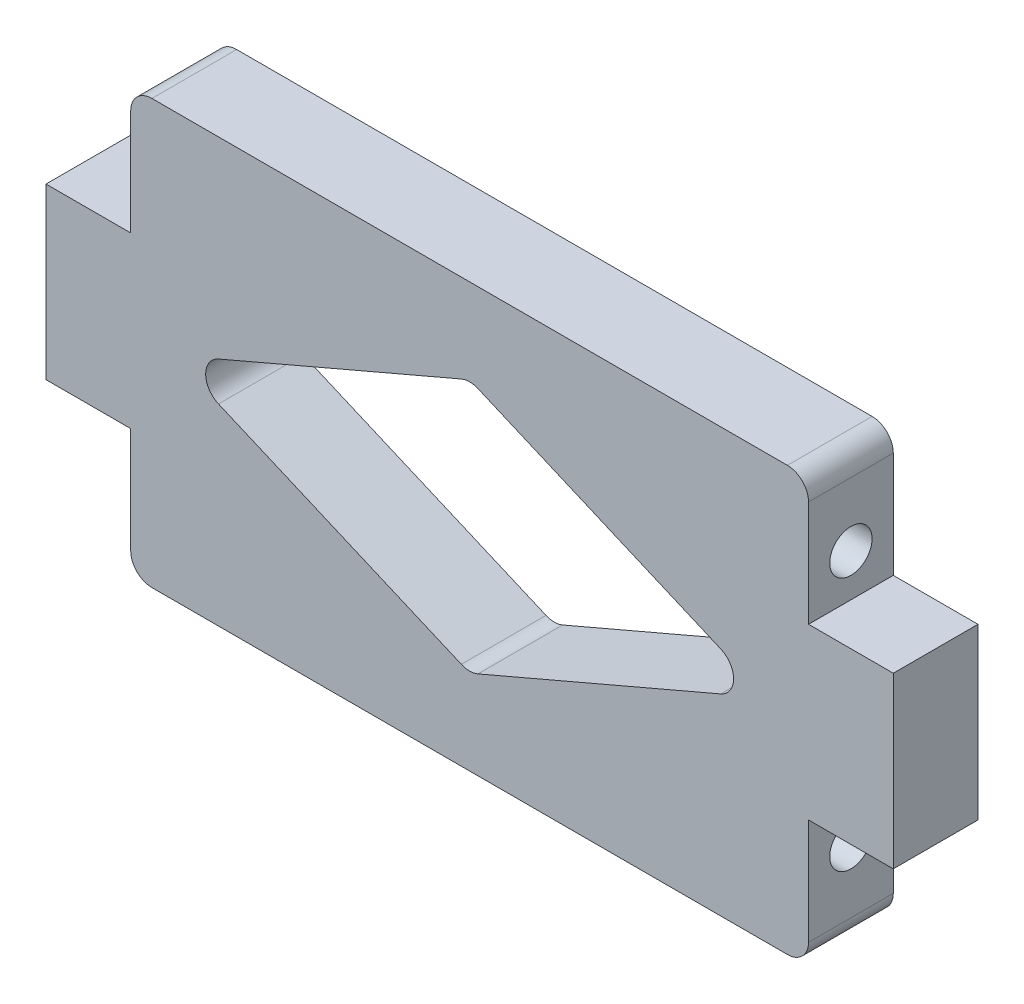
from build123d import *

# Parameters (mm, degrees)
SKETCH1_W                        = 12.7
SKETCH1_H                        = 25.4
SKETCH1_W_2                      = 101.6
SKETCH1_H_2                      = 63.5
BOSS_EXTRUDE1_DEPTH              = 12.7
F_1_4_20_TAPPED_HOLE1_AT_2_COUNT = 2
F_1_4_20_TAPPED_HOLE1_AT_2_PITCH = 38.1
CUT_EXTRUDE1_DEPTH               = 13.7
FILLET1_R                        = 3.175
FILLET2_R                        = 3.175


with BuildPart() as part:
    # Sketch1 → Boss-Extrude1 (new body)
    with BuildSketch(Plane.XY):
        with Locations((-57.15, 0)):
            Rectangle(SKETCH1_W, SKETCH1_H)
        Rectangle(SKETCH1_W_2, SKETCH1_H_2)
        with Locations((57.15, 0)):
            Rectangle(SKETCH1_W, SKETCH1_H)
    extrude(amount=BOSS_EXTRUDE1_DEPTH)

    # Sketch2 → 1/4-20 Tapped Hole1 (revolve, cut)
    with BuildSketch(Plane(origin=(50.8, 19.05, 6.35), x_dir=(0, 0, -1), z_dir=(0, 1, 0))):
        Polygon((0, 0), (0, 18.043816902), (2.5527, 16.51), (2.5527, 12.7), (3.175, 12.7), (3.175, 0), align=None)
    f_1_4_20_tapped_hole1 = revolve(axis=Axis((57.15, 19.05, 6.35), (-1, 0, 0)), mode=Mode.SUBTRACT)

    # 1/4-20 Tapped Hole1 at 2: 1/4-20 Tapped Hole1 ×2
    with Locations(*[(0, -i * F_1_4_20_TAPPED_HOLE1_AT_2_PITCH, 0) for i in range(1, F_1_4_20_TAPPED_HOLE1_AT_2_COUNT)]):
        add(f_1_4_20_tapped_hole1, mode=Mode.SUBTRACT)

    # Mirror1: 1/4-20 Tapped Hole1 across plane
    add(f_1_4_20_tapped_hole1.mirror(Plane(origin=(0, 0, 0), x_dir=(0, 0, 1), z_dir=(1, 0, 0))), mode=Mode.SUBTRACT)

    # Mirror1 copy 1 sketch → Mirror1 copy 1 (revolve, cut)
    with BuildSketch(Plane(origin=(-50.8, -19.05, 6.35), x_dir=(0, 0, -1), z_dir=(0, 1, 0))):
        Polygon((0, 0), (0, -18.043816902), (2.5527, -16.51), (2.5527, -12.7), (3.175, -12.7), (3.175, 0), align=None)
    revolve(axis=Axis((-57.15, -19.05, 6.35), (-1, 0, 0)), mode=Mode.SUBTRACT)

    # Sketch4 → Cut-Extrude1 (cut, through all)
    with BuildSketch(Plane.XY.offset(12.7)):
        Polygon((-44.45, 0), (0, 19.05), (44.45, 0), (0, -19.05), align=None)
    extrude(amount=-CUT_EXTRUDE1_DEPTH, mode=Mode.SUBTRACT)

    # Fillet1
    fillet1_edges = [part.edges().sort_by_distance(p)[0] for p in [
        (0, 19.05, 6.35),
        (44.45, 0, 6.35),
        (0, -19.05, 6.35),
        (-44.45, 0, 6.35),
    ]]
    fillet(fillet1_edges, radius=FILLET1_R)

    # Fillet2
    fillet2_edges = [part.edges().sort_by_distance(p)[0] for p in [
        (-50.8, 31.75, 6.35),
        (50.8, 31.75, 6.35),
        (50.8, -31.75, 6.35),
        (-50.8, -31.75, 6.35),
    ]]
    fillet(fillet2_edges, radius=FILLET2_R)


solid = part.part
